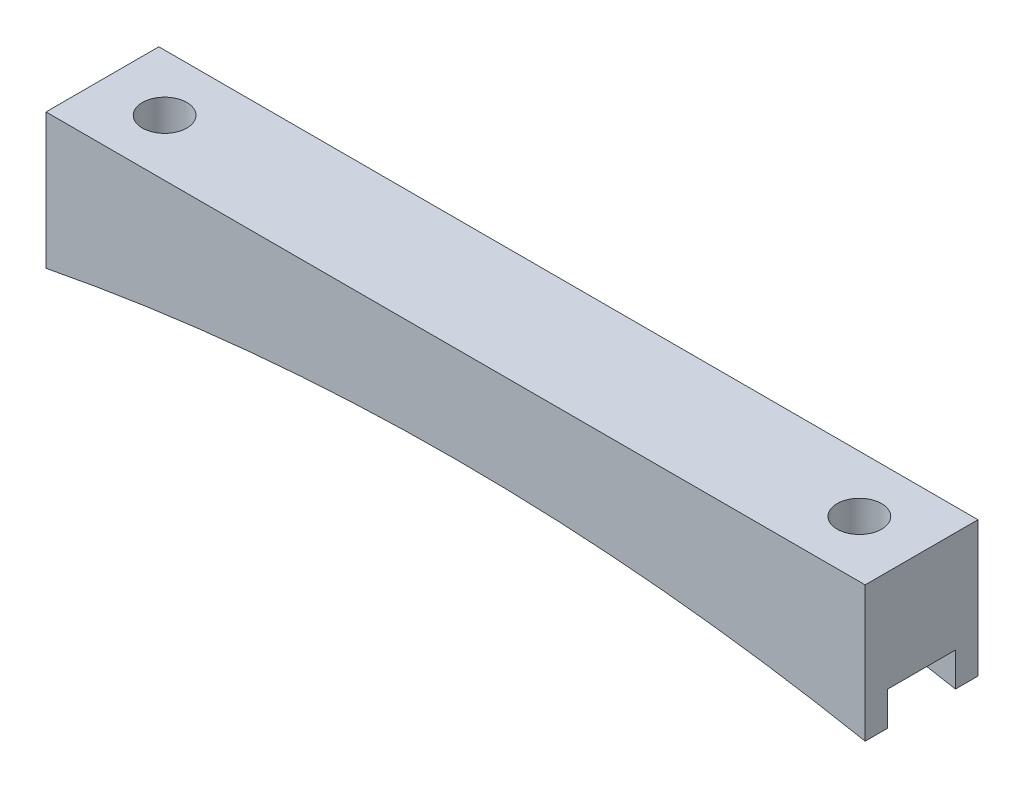
from build123d import *

# Parameters (mm, degrees)
BOSS_EXTRUDE1_DEPTH = 12.7
SKETCH2_R           = 2.5
CUT_EXTRUDE1_DEPTH  = 16.24
SKETCH3_W           = 7.62
SKETCH3_H           = 3.81
CUT_EXTRUDE2_DEPTH  = 93.1900001


with BuildPart() as part:
    # Sketch1 → Boss-Extrude1 (new body)
    with BuildSketch(Plane.XY):
        with BuildLine():
            Line((-46.095, 0), (46.095, 0))
            Line((46.095, 0), (46.095, -15.24))
            ThreePointArc((46.095, -15.24), (0, -10.796372038), (-46.095, -15.24))
            Line((-46.095, -15.24), (-46.095, 0))
        make_face()
    extrude(amount=BOSS_EXTRUDE1_DEPTH)

    # Sketch2 → Cut-Extrude1 (cut, through all)
    with BuildSketch(Plane(origin=(0, 0, 0), x_dir=(1, 0, 0), z_dir=(0, 1, 0))):
        with Locations((-39.095, -6.35)):
            Circle(SKETCH2_R)
        with Locations((39.095, -6.35)):
            Circle(SKETCH2_R)
    extrude(amount=-CUT_EXTRUDE1_DEPTH, mode=Mode.SUBTRACT)

    # Sketch3 → Cut-Extrude2 (cut, through all)
    with BuildSketch(Plane(origin=(46.095, 0, 0), x_dir=(0, 0, -1), z_dir=(1, 0, 0))):
        with Locations((-6.35, -13.335)):
            Rectangle(SKETCH3_W, SKETCH3_H)
    extrude(amount=-CUT_EXTRUDE2_DEPTH, mode=Mode.SUBTRACT)


solid = part.part
